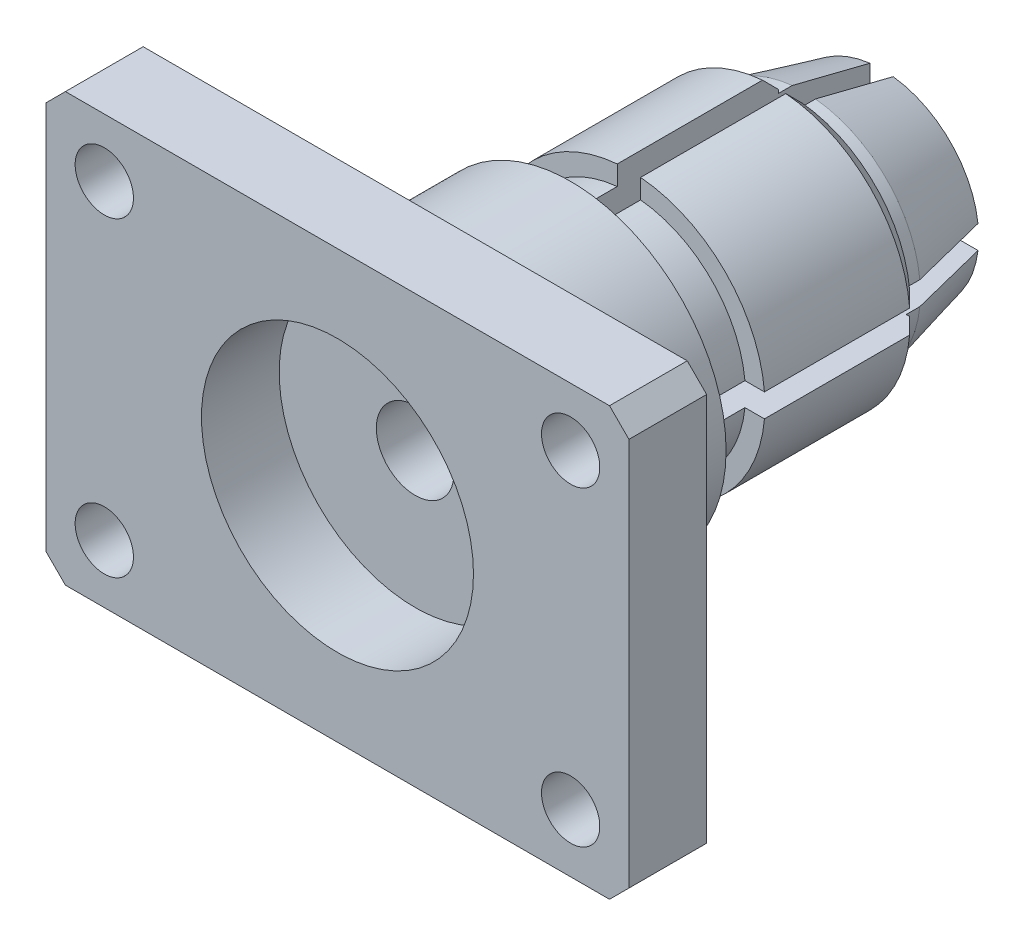
from build123d import *

# Parameters (mm, degrees)
SKETCH_1_W                 = 15
SKETCH_1_H                 = 22
SKETCH_1_R                 = 1.5
EXTRUDE_1_DEPTH            = 4
CHAMFER_1_SIZE             = 1
CHAMFER_1_OF_MIRROR_1_SIZE = 1
SKETCH_2_R                 = 2
CUT_EXTRUDE_1_DEPTH        = 5
SKETCH_3_R                 = 8
SKETCH_3_R_2               = 2
EXTRUDE_2_DEPTH            = 8
EXTRUDE_3_DEPTH            = 16
CHAMFER_2_SIZE             = 4
CHAMFER_2_SIZE2            = 1
EXTRUDE_START              = 3
SKETCH_5_R                 = 7
SKETCH_5_R_2               = 4.5
EXTRUDE_4_DEPTH            = 8.3
CHAMFER_3_SIZE             = 0.828
SKETCH_6_R                 = 4.5
SKETCH_6_R_2               = 3.4455
EXTRUDE_5_DEPTH            = 11.8
CHAMFER_4_SIZE             = 0.5545
CUT_EXTRUDE_3_DEPTH        = 17
SKETCH_7_R                 = 7
CUT_EXTRUDE_4_DEPTH        = 4


with BuildPart() as part:
    # Эскиз1 → Бобышка-Вытянуть1 (new body)
    with BuildSketch(Plane.XY):
        Rectangle(SKETCH_1_W, SKETCH_1_H)
        with Locations((-4.5, 8)):
            Circle(SKETCH_1_R, mode=Mode.SUBTRACT)
        with Locations((-4.5, -8)):
            Circle(SKETCH_1_R, mode=Mode.SUBTRACT)
    extrude_1 = extrude(amount=EXTRUDE_1_DEPTH)

    # Фаска1
    chamfer_1_edges = [part.edges().sort_by_distance(p)[0] for p in [
        (-7.5, -11, 2),
        (-7.5, 11, 2),
    ]]
    chamfer(chamfer_1_edges, length=CHAMFER_1_SIZE)

    # Зеркальное отражение1: Бобышка-Вытянуть1 across plane
    add(extrude_1.mirror(Plane(origin=(7.5, -11, 4), x_dir=(0, 0, 1), z_dir=(-1, 0, 0))))

    # Фаска1 of Зеркальное отражение1
    chamfer_1_of_mirror_1_edges = [part.edges().sort_by_distance(p)[0] for p in [
        (22.5, -11, 2),
        (22.5, 11, 2),
    ]]
    chamfer(chamfer_1_of_mirror_1_edges, length=CHAMFER_1_OF_MIRROR_1_SIZE)

    # Эскиз2 → Вырез-Вытянуть1 (cut, through all)
    with BuildSketch(Plane(origin=(0, 0, 0), x_dir=(-1, 0, 0), z_dir=(0, 0, -1))):
        with Locations((-7.5, 0)):
            Circle(SKETCH_2_R)
    extrude(amount=-CUT_EXTRUDE_1_DEPTH, mode=Mode.SUBTRACT)

    # Эскиз3 → Бобышка-Вытянуть2 (add)
    with BuildSketch(Plane(origin=(0, 0, 0), x_dir=(-1, 0, 0), z_dir=(0, 0, -1))):
        with Locations((-7.5, 0)):
            Circle(SKETCH_3_R)
        with Locations((-7.5, 0)):
            Circle(SKETCH_3_R_2, mode=Mode.SUBTRACT)
    extrude(amount=EXTRUDE_2_DEPTH)

    # Эскиз4 → Бобышка-Вытянуть3 (add)
    with BuildSketch(Plane(origin=(0, 0, -8), x_dir=(-1, 0, 0), z_dir=(0, 0, -1))):
        with BuildLine():
            Line((-8.1, 4.459820624), (-8.1, 5.969924623))
            ThreePointArc((-8.1, 5.969924623), (-11.742640687, 4.242640687), (-13.469924623, 0.6))
            Line((-13.469924623, 0.6), (-11.959820624, 0.6))
            ThreePointArc((-11.959820624, 0.6), (-10.681980515, 3.181980515), (-8.1, 4.459820624))
        make_face()
        with BuildLine():
            Line((-6.9, 4.459820624), (-6.9, 5.969924623))
            ThreePointArc((-6.9, 5.969924623), (-7.5, 6), (-8.1, 5.969924623))
            Line((-8.1, 5.969924623), (-8.1, 4.459820624))
            ThreePointArc((-8.1, 4.459820624), (-7.5, 4.5), (-6.9, 4.459820624))
        make_face()
        with BuildLine():
            ThreePointArc((-8.1, -5.969924623), (-7.5, -6), (-6.9, -5.969924623))
            Line((-6.9, -5.969924623), (-6.9, -4.459820624))
            ThreePointArc((-6.9, -4.459820624), (-7.5, -4.5), (-8.1, -4.459820624))
            Line((-8.1, -4.459820624), (-8.1, -5.969924623))
        make_face()
        with BuildLine():
            Line((-3.040179376, 0.6), (-1.530075377, 0.6))
            ThreePointArc((-1.530075377, 0.6), (-3.257359313, 4.242640687), (-6.9, 5.969924623))
            Line((-6.9, 5.969924623), (-6.9, 4.459820624))
            ThreePointArc((-6.9, 4.459820624), (-4.318019485, 3.181980515), (-3.040179376, 0.6))
        make_face()
        with BuildLine():
            ThreePointArc((-1.5, 0), (-1.507523561, 0.30037665), (-1.530075377, 0.6))
            Line((-1.530075377, 0.6), (-3.040179376, 0.6))
            ThreePointArc((-3.040179376, 0.6), (-3.01005608, 0.300671907), (-3, 0))
            ThreePointArc((-3, 0), (-3.01005608, -0.300671907), (-3.040179376, -0.6))
            Line((-3.040179376, -0.6), (-1.530075377, -0.6))
            ThreePointArc((-1.530075377, -0.6), (-1.507523561, -0.30037665), (-1.5, 0))
        make_face()
        with BuildLine():
            Line((-11.959820624, 0.6), (-13.469924623, 0.6))
            ThreePointArc((-13.469924623, 0.6), (-13.5, 0), (-13.469924623, -0.6))
            Line((-13.469924623, -0.6), (-11.959820624, -0.6))
            ThreePointArc((-11.959820624, -0.6), (-12, 0), (-11.959820624, 0.6))
        make_face()
        with BuildLine():
            ThreePointArc((-6.9, -5.969924623), (-3.257359313, -4.242640687), (-1.530075377, -0.6))
            Line((-1.530075377, -0.6), (-3.040179376, -0.6))
            ThreePointArc((-3.040179376, -0.6), (-4.318019485, -3.181980515), (-6.9, -4.459820624))
            Line((-6.9, -4.459820624), (-6.9, -5.969924623))
        make_face()
        with BuildLine():
            ThreePointArc((-13.469924623, -0.6), (-11.742640687, -4.242640687), (-8.1, -5.969924623))
            Line((-8.1, -5.969924623), (-8.1, -4.459820624))
            ThreePointArc((-8.1, -4.459820624), (-10.681980515, -3.181980515), (-11.959820624, -0.6))
            Line((-11.959820624, -0.6), (-13.469924623, -0.6))
        make_face()
    extrude(amount=EXTRUDE_3_DEPTH)

    # Фаска2
    chamfer_2_edges = [part.edges().sort_by_distance(p)[0] for p in [
        (2.854361747, 3.797110115, -24),
    ]]
    chamfer_2_side = [part.faces().sort_by_distance(p)[0] for p in [
        (2.854361747, 3.797110115, -16),
    ]]
    chamfer(chamfer_2_edges, length=CHAMFER_2_SIZE, length2=CHAMFER_2_SIZE2, reference=chamfer_2_side[0])

    # Эскиз5 → Бобышка-Вытянуть4 (add)
    with BuildSketch(Plane(origin=(0, 0, -8), x_dir=(-1, 0, 0), z_dir=(0, 0, -1)).offset(EXTRUDE_START)):
        with Locations((-7.5, 0)):
            Circle(SKETCH_5_R)
        with Locations((-7.5, 0)):
            Circle(SKETCH_5_R_2, mode=Mode.SUBTRACT)
    extrude(amount=EXTRUDE_4_DEPTH)

    # Фаска3
    chamfer_3_edges = [part.edges().sort_by_distance(p)[0] for p in [
        (14.5, 0, -19.3),
    ]]
    chamfer(chamfer_3_edges, length=CHAMFER_3_SIZE)

    # Эскиз6 → Бобышка-Вытянуть5 (add)
    with BuildSketch(Plane(origin=(0, 0, -24), x_dir=(-1, 0, 0), z_dir=(0, 0, -1))):
        with Locations((-7.5, 0)):
            Circle(SKETCH_6_R)
        with Locations((-7.5, 0)):
            Circle(SKETCH_6_R_2, mode=Mode.SUBTRACT)
    extrude(amount=-EXTRUDE_5_DEPTH)

    # Фаска4
    chamfer_4_edges = [part.edges().sort_by_distance(p)[0] for p in [
        (10.9455, 0, -24),
    ]]
    chamfer(chamfer_4_edges, length=CHAMFER_4_SIZE)

    # Эскиз4<4> → Вырез-Вытянуть3 (cut, through all)
    with BuildSketch(Plane(origin=(0, 0, -8), x_dir=(-1, 0, 0), z_dir=(0, 0, -1))):
        with BuildLine():
            Line((-6.9, 5.969924623), (-6.9, 7.97746827))
            ThreePointArc((-6.9, 7.97746827), (-7.199788542, 7.994365083), (-7.5, 8))
            ThreePointArc((-7.5, 8), (-7.800211458, 7.994365083), (-8.1, 7.97746827))
            Line((-8.1, 7.97746827), (-8.1, 5.969924623))
            ThreePointArc((-8.1, 5.969924623), (-7.5, 6), (-6.9, 5.969924623))
        make_face()
        with BuildLine():
            ThreePointArc((-7.5, -8), (-7.199788542, -7.994365083), (-6.9, -7.97746827))
            Line((-6.9, -7.97746827), (-6.9, -5.969924623))
            ThreePointArc((-6.9, -5.969924623), (-7.5, -6), (-8.1, -5.969924623))
            Line((-8.1, -5.969924623), (-8.1, -7.97746827))
            ThreePointArc((-8.1, -7.97746827), (-7.800211458, -7.994365083), (-7.5, -8))
        make_face()
        with BuildLine():
            Line((-6.9, 4.459820624), (-6.9, 5.969924623))
            ThreePointArc((-6.9, 5.969924623), (-7.5, 6), (-8.1, 5.969924623))
            Line((-8.1, 5.969924623), (-8.1, 4.459820624))
            ThreePointArc((-8.1, 4.459820624), (-7.5, 4.5), (-6.9, 4.459820624))
        make_face()
        with BuildLine():
            ThreePointArc((-8.1, -5.969924623), (-7.5, -6), (-6.9, -5.969924623))
            Line((-6.9, -5.969924623), (-6.9, -4.459820624))
            ThreePointArc((-6.9, -4.459820624), (-7.5, -4.5), (-8.1, -4.459820624))
            Line((-8.1, -4.459820624), (-8.1, -5.969924623))
        make_face()
        with BuildLine():
            Line((-6.9, 1.907878403), (-6.9, 4.459820624))
            ThreePointArc((-6.9, 4.459820624), (-7.5, 4.5), (-8.1, 4.459820624))
            Line((-8.1, 4.459820624), (-8.1, 1.907878403))
            ThreePointArc((-8.1, 1.907878403), (-7.5, 2), (-6.9, 1.907878403))
        make_face()
        with BuildLine():
            ThreePointArc((-8.1, -4.459820624), (-7.5, -4.5), (-6.9, -4.459820624))
            Line((-6.9, -4.459820624), (-6.9, -1.907878403))
            ThreePointArc((-6.9, -1.907878403), (-7.5, -2), (-8.1, -1.907878403))
            Line((-8.1, -1.907878403), (-8.1, -4.459820624))
        make_face()
        with BuildLine():
            ThreePointArc((0.5, 0), (0.494365083, 0.300211458), (0.47746827, 0.6))
            Line((0.47746827, 0.6), (-1.530075377, 0.6))
            ThreePointArc((-1.530075377, 0.6), (-1.507523561, 0.30037665), (-1.5, 0))
            ThreePointArc((-1.5, 0), (-1.507523561, -0.30037665), (-1.530075377, -0.6))
            Line((-1.530075377, -0.6), (0.47746827, -0.6))
            ThreePointArc((0.47746827, -0.6), (0.494365083, -0.300211458), (0.5, 0))
        make_face()
        with BuildLine():
            ThreePointArc((-13.469924623, -0.6), (-13.5, 0), (-13.469924623, 0.6))
            Line((-13.469924623, 0.6), (-15.47746827, 0.6))
            ThreePointArc((-15.47746827, 0.6), (-15.494365083, 0.300211458), (-15.5, 0))
            ThreePointArc((-15.5, 0), (-15.494365083, -0.300211458), (-15.47746827, -0.6))
            Line((-15.47746827, -0.6), (-13.469924623, -0.6))
        make_face()
        with BuildLine():
            ThreePointArc((-1.5, 0), (-1.507523561, 0.30037665), (-1.530075377, 0.6))
            Line((-1.530075377, 0.6), (-3.040179376, 0.6))
            ThreePointArc((-3.040179376, 0.6), (-3.01005608, 0.300671907), (-3, 0))
            ThreePointArc((-3, 0), (-3.01005608, -0.300671907), (-3.040179376, -0.6))
            Line((-3.040179376, -0.6), (-1.530075377, -0.6))
            ThreePointArc((-1.530075377, -0.6), (-1.507523561, -0.30037665), (-1.5, 0))
        make_face()
        with BuildLine():
            Line((-11.959820624, 0.6), (-13.469924623, 0.6))
            ThreePointArc((-13.469924623, 0.6), (-13.5, 0), (-13.469924623, -0.6))
            Line((-13.469924623, -0.6), (-11.959820624, -0.6))
            ThreePointArc((-11.959820624, -0.6), (-12, 0), (-11.959820624, 0.6))
        make_face()
        with BuildLine():
            ThreePointArc((-3, 0), (-3.01005608, 0.300671907), (-3.040179376, 0.6))
            Line((-3.040179376, 0.6), (-5.592121597, 0.6))
            ThreePointArc((-5.592121597, 0.6), (-5.523164548, 0.303515399), (-5.5, 0))
            ThreePointArc((-5.5, 0), (-5.523164548, -0.303515399), (-5.592121597, -0.6))
            Line((-5.592121597, -0.6), (-3.040179376, -0.6))
            ThreePointArc((-3.040179376, -0.6), (-3.01005608, -0.300671907), (-3, 0))
        make_face()
        with BuildLine():
            Line((-9.407878403, 0.6), (-11.959820624, 0.6))
            ThreePointArc((-11.959820624, 0.6), (-12, 0), (-11.959820624, -0.6))
            Line((-11.959820624, -0.6), (-9.407878403, -0.6))
            ThreePointArc((-9.407878403, -0.6), (-9.5, 0), (-9.407878403, 0.6))
        make_face()
    extrude(amount=CUT_EXTRUDE_3_DEPTH, mode=Mode.SUBTRACT)

    # Эскиз7 → Вырез-Вытянуть4 (cut)
    with BuildSketch(Plane.XY.offset(4)):
        with Locations((7.5, 0)):
            Circle(SKETCH_7_R)
    extrude(amount=-CUT_EXTRUDE_4_DEPTH, mode=Mode.SUBTRACT)


solid = part.part
